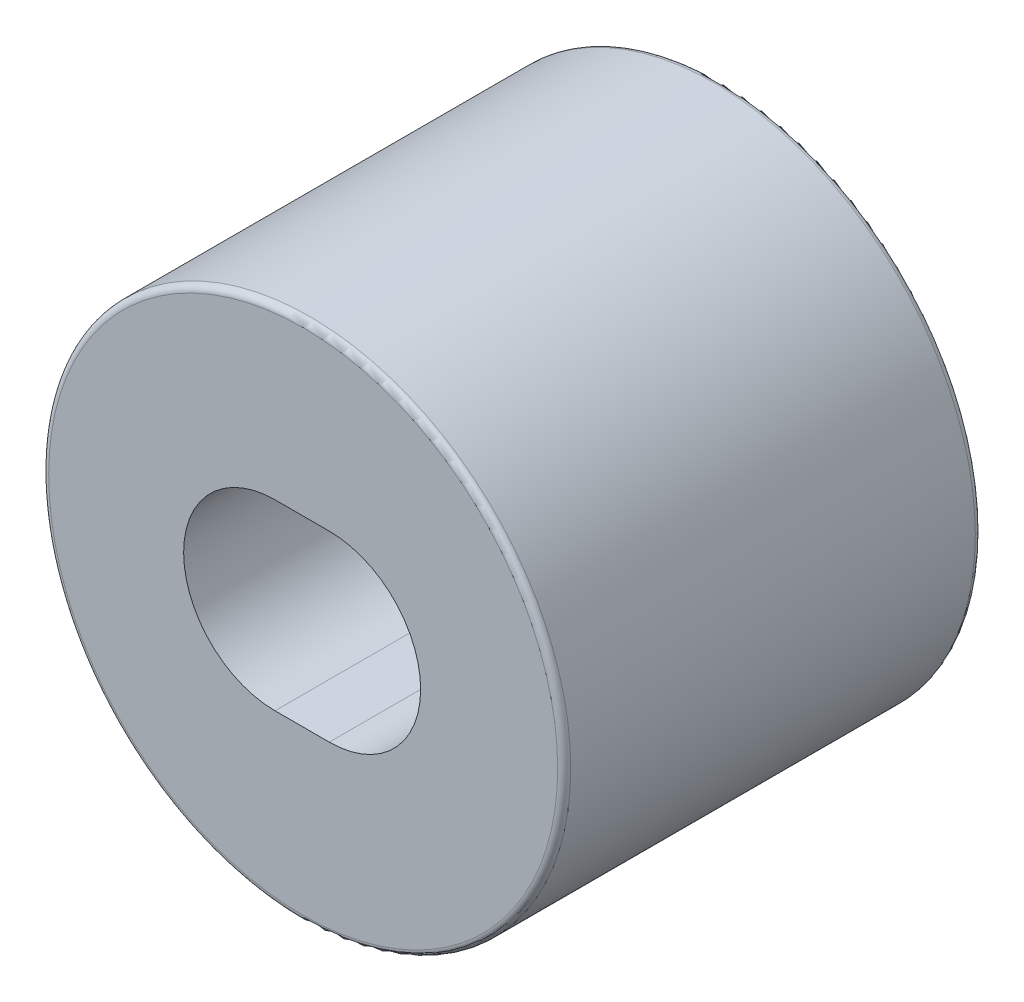
from build123d import *

# Parameters (mm, degrees)
SKETCH1_R           = 5
BOSS_EXTRUDE1_DEPTH = 8
FILLET1_R           = 0.125
SKETCH4_R           = 2
CUT_EXTRUDE1_DEPTH  = 2.5


with BuildPart() as part:
    # Sketch1 → Boss-Extrude1 (new body)
    with BuildSketch(Plane.XY):
        Circle(SKETCH1_R)
        with BuildLine():
            ThreePointArc((0.5, -1.75), (2.25, 0), (0.5, 1.75))
            Line((0.5, 1.75), (-0.5402042, 1.75))
            ThreePointArc((-0.5402042, 1.75), (-2.2902042, 0), (-0.5402042, -1.75))
            Line((-0.5402042, -1.75), (0.5, -1.75))
        make_face(mode=Mode.SUBTRACT)
    extrude(amount=BOSS_EXTRUDE1_DEPTH)

    # Fillet1
    fillet1_edges = [part.edges().sort_by_distance(p)[0] for p in [
        (-5, 0, 8),
        (-5, 0, 0),
    ]]
    fillet(fillet1_edges, radius=FILLET1_R)

    # Sketch4 → Cut-Extrude1 (cut)
    with BuildSketch(Plane.XZ.offset(5)):
        with Locations((0, 4)):
            Circle(SKETCH4_R)
    extrude(amount=-CUT_EXTRUDE1_DEPTH, mode=Mode.SUBTRACT)


solid = part.part
